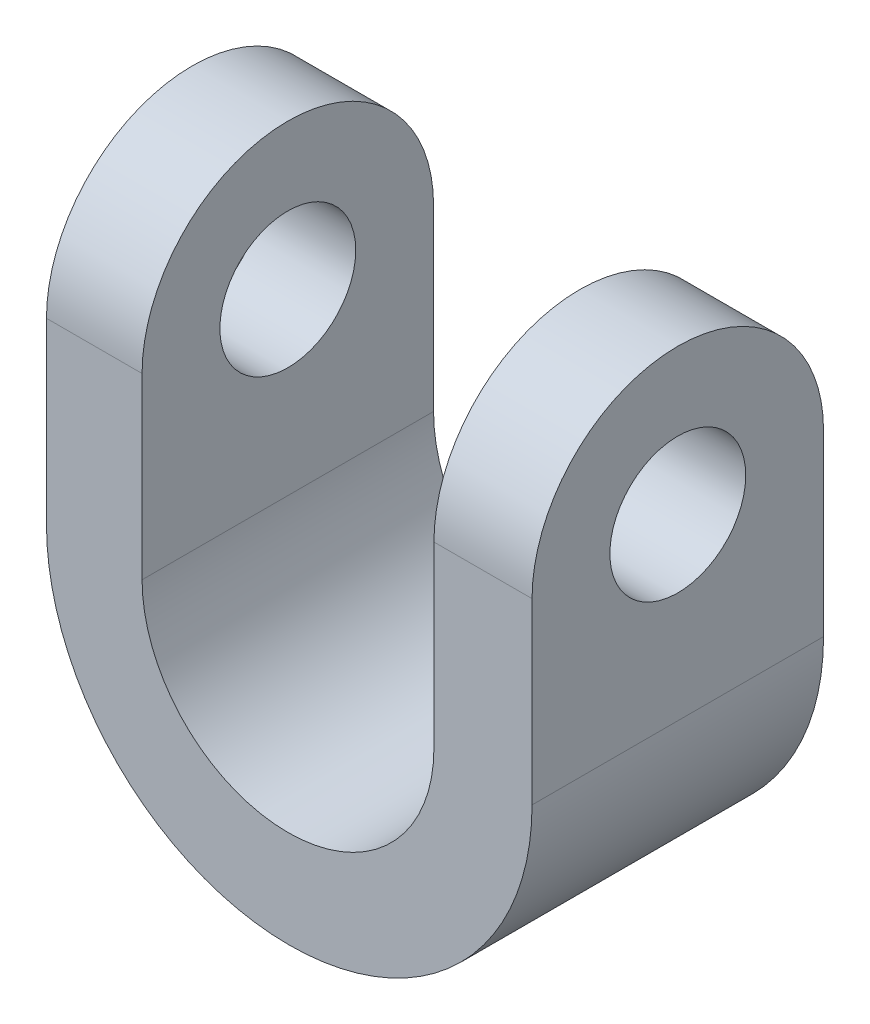
from build123d import *

# Parameters (mm, degrees)
BOSS_EXTRUDE1_DEPTH = 80
CUT_EXTRUDE4_DEPTH  = 86.022442091
SKETCH3_W           = 85.02244209
SKETCH3_H           = 14.481412897
CUT_EXTRUDE5_DEPTH  = 61.793248749
SKETCH4_R           = 11.893880873
CUT_EXTRUDE6_DEPTH  = 86.022442091


with BuildPart() as part:
    # Sketch1 → Boss-Extrude1 (new body)
    with BuildSketch(Plane.XY):
        with BuildLine():
            Line((40.088301711, 44.273344197), (40.088301711, -18.282027703))
            ThreePointArc((40.088301711, -18.282027703), (-2.422919334, -60.793248749), (-44.934140379, -18.282027703))
            Line((-44.934140379, -18.282027703), (-44.934140379, 44.273344197))
            Line((-44.934140379, 44.273344197), (-28.193970434, 44.273344197))
            Line((-28.193970434, 44.273344197), (-28.193970434, -18.282027703))
            ThreePointArc((-28.193970434, -18.282027703), (-2.643184728, -43.832813409), (22.907600978, -18.282027703))
            Line((22.907600978, -18.282027703), (22.907600978, 44.273344197))
            Line((22.907600978, 44.273344197), (40.088301711, 44.273344197))
        make_face()
    extrude(amount=-BOSS_EXTRUDE1_DEPTH)

    # Sketch2 → Cut-Extrude4 (cut, through all)
    with BuildSketch(Plane(origin=(40.088301711, 0, 0), x_dir=(0, 0, -1), z_dir=(1, 0, 0))):
        with BuildLine():
            Line((14.481412897, -18.282027703), (14.481412897, 12.995658247))
            ThreePointArc((14.481412897, 12.995658247), (40, 38.51424535), (65.518587103, 12.995658247))
            Line((65.518587103, 12.995658247), (65.518587103, -18.282027703))
            Line((65.518587103, -18.282027703), (80, -18.282027703))
            Line((80, -18.282027703), (80, 44.273344197))
            Line((80, 44.273344197), (0, 44.273344197))
            Line((0, 44.273344197), (0, -18.282027703))
            Line((0, -18.282027703), (14.481412897, -18.282027703))
        make_face()
    extrude(amount=-CUT_EXTRUDE4_DEPTH, mode=Mode.SUBTRACT)

    # Sketch3 → Cut-Extrude5 (cut, through all)
    with BuildSketch(Plane(origin=(0, 0, 0), x_dir=(1, 0, 0), z_dir=(0, 1, 0))):
        with Locations((-2.422919334, 7.240706449)):
            Rectangle(SKETCH3_W, SKETCH3_H)
        with Locations((-2.422919334, 72.759293552)):
            Rectangle(SKETCH3_W, SKETCH3_H)
    extrude(amount=-CUT_EXTRUDE5_DEPTH, mode=Mode.SUBTRACT)

    # Sketch4 → Cut-Extrude6 (cut, through all)
    with BuildSketch(Plane(origin=(40.088301711, 0, 0), x_dir=(0, 0, -1), z_dir=(1, 0, 0))):
        with Locations((40, 12.995658247)):
            Circle(SKETCH4_R)
    extrude(amount=-CUT_EXTRUDE6_DEPTH, mode=Mode.SUBTRACT)


solid = part.part
